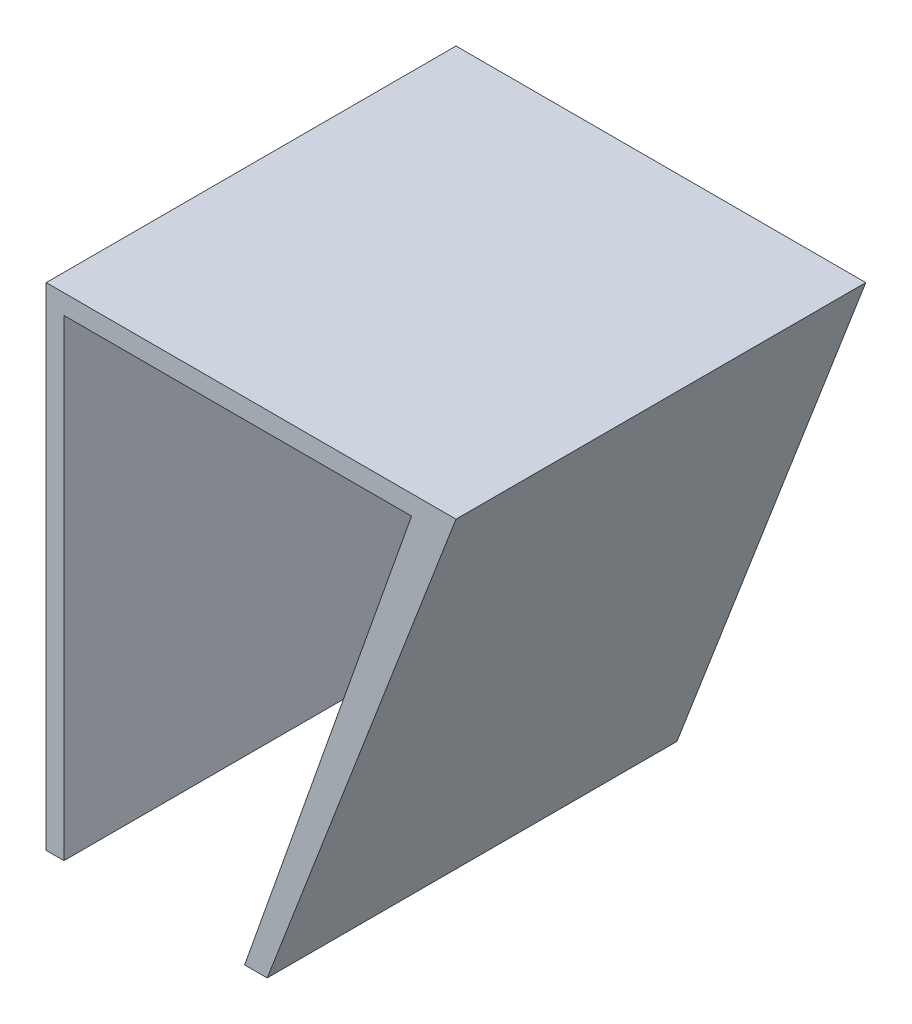
from build123d import *

# Parameters (mm, degrees)
BOSS_EXTRUDE4_DEPTH = 38.1


with BuildPart() as part:
    # Sketch1 → Boss-Extrude4 (new body)
    with BuildSketch(Plane.XY):
        Polygon((0, 0), (0, 45.72), (38.1, 45.72), (20.545025808, 0), (18.446289243, 0), (33.966686375, 43.900222239), (1.649727133, 43.900222239), (1.649727133, 0), align=None)
    extrude(amount=BOSS_EXTRUDE4_DEPTH)


solid = part.part
